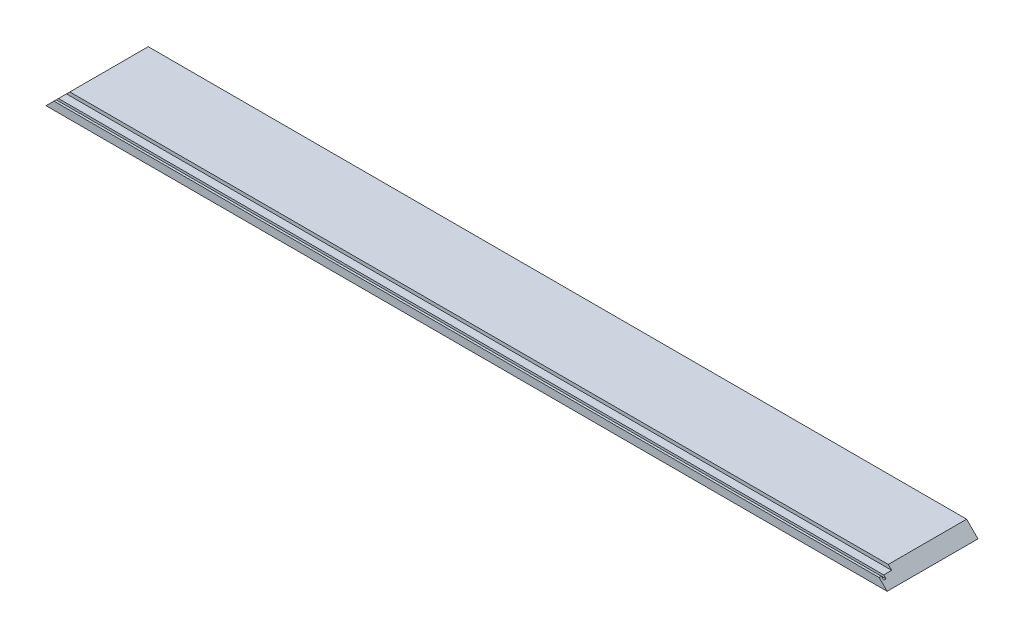
from build123d import *

# Parameters (mm, degrees)
SKETCH1_W           = 740.5
SKETCH1_H           = 80
BOSS_EXTRUDE1_DEPTH = 10
SKETCH2_W           = 11
SKETCH2_H           = 3
CUT_EXTRUDE1_DEPTH  = 741.5
SKETCH3_W           = 2
SKETCH3_H           = 2
CUT_EXTRUDE2_DEPTH  = 741.5
CUT_EXTRUDE4_DEPTH  = 81


with BuildPart() as part:
    # Sketch1 → Boss-Extrude1 (new body)
    with BuildSketch(Plane(origin=(0, 0, 0), x_dir=(1, 0, 0), z_dir=(0, 1, 0))):
        Rectangle(SKETCH1_W, SKETCH1_H)
    extrude(amount=BOSS_EXTRUDE1_DEPTH)

    # Sketch2 → Cut-Extrude1 (cut, through all)
    with BuildSketch(Plane.ZY.offset(370.25)):
        with Locations((34.5, 8.5)):
            Rectangle(SKETCH2_W, SKETCH2_H)
    extrude(amount=-CUT_EXTRUDE1_DEPTH, mode=Mode.SUBTRACT)

    # Sketch3 → Cut-Extrude2 (cut, through all)
    with BuildSketch(Plane.ZY.offset(370.25)):
        with Locations((37, 6)):
            Rectangle(SKETCH3_W, SKETCH3_H)
    extrude(amount=-CUT_EXTRUDE2_DEPTH, mode=Mode.SUBTRACT)

    # Sketch4 → Cut-Extrude4 (cut, through all)
    with BuildSketch(Plane(origin=(0, 0, -40), x_dir=(-1, 0, 0), z_dir=(0, 0, -1))):
        Polygon((-370.25, 0), (-360.25, 10), (-370.25, 10), align=None)
        Polygon((370.25, 10), (370.25, 0), (360.25, 10), align=None)
    extrude(amount=-CUT_EXTRUDE4_DEPTH, mode=Mode.SUBTRACT)


solid = part.part
